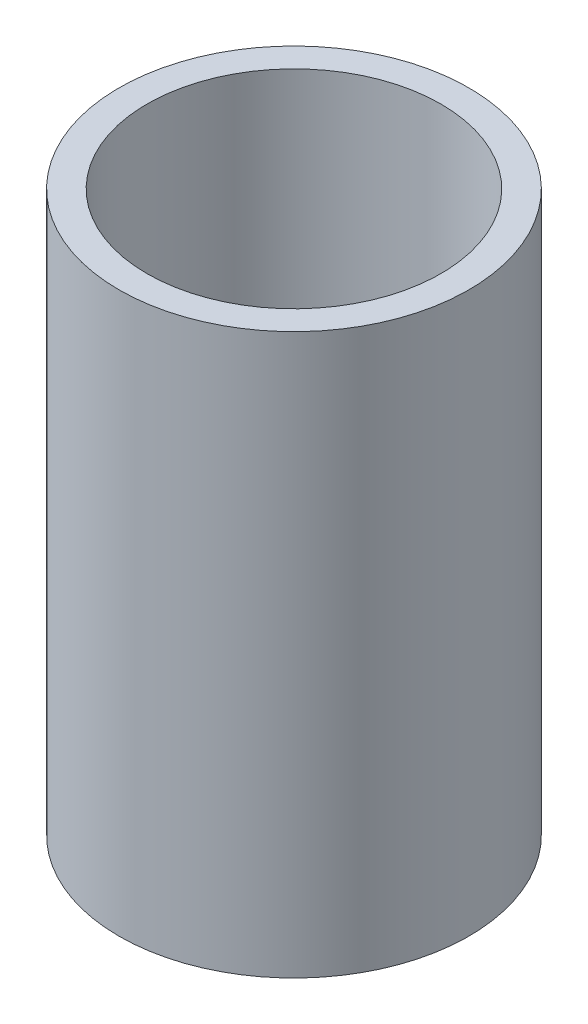
from build123d import *

# Parameters (mm, degrees)
SKETCH_1_R      = 12.5
SKETCH_1_R_2    = 10.5
EXTRUDE_1_DEPTH = 40


with BuildPart() as part:
    # 草图1 → 凸台-拉伸1 (new body)
    with BuildSketch(Plane(origin=(0, 0, 0), x_dir=(1, 0, 0), z_dir=(0, 1, 0))):
        Circle(SKETCH_1_R)
        Circle(SKETCH_1_R_2, mode=Mode.SUBTRACT)
    extrude(amount=EXTRUDE_1_DEPTH)


solid = part.part
